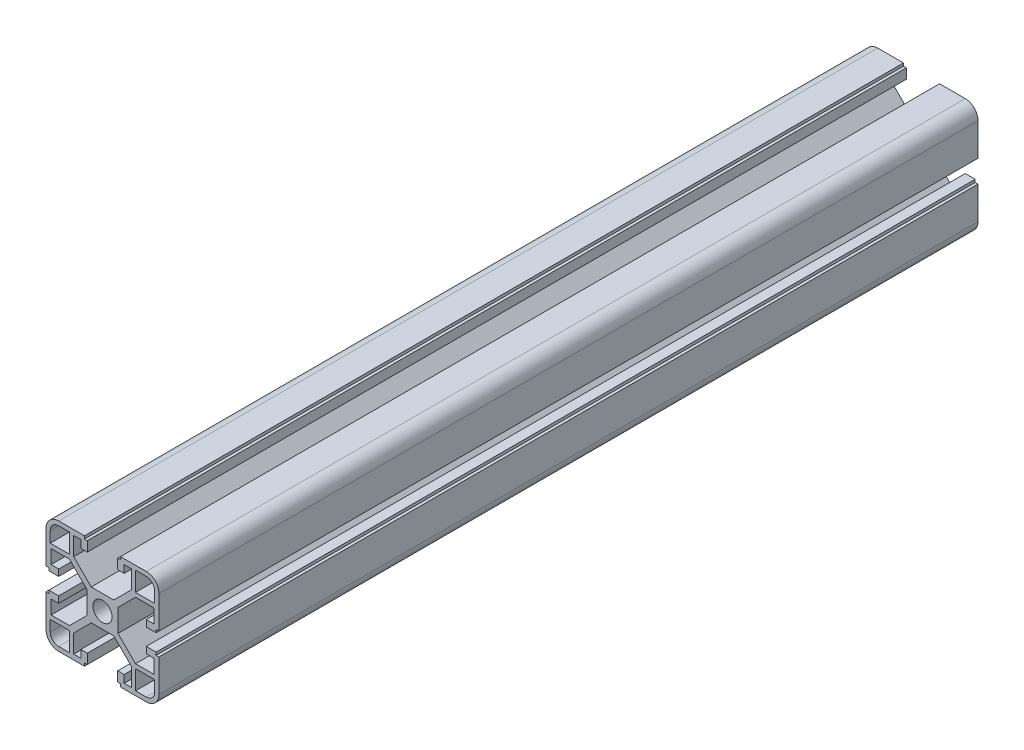
from build123d import *

# Parameters (mm, degrees)
BOSS_EXTRUDE1_DEPTH  = 290
MIRROR3_COPY_1_DEPTH = 290
MIRROR3_COPY_2_DEPTH = 290


with BuildPart() as part:
    # Sketch1 → Boss-Extrude1 (new body)
    with BuildSketch(Plane.XY):
        with BuildLine():
            Line((3.4, 0), (5.5, 0))
            Line((5.5, 0), (5.5, 4))
            Line((5.5, 4), (11.69, 10.19))
            Line((11.69, 10.19), (18.2, 10.19))
            Line((18.2, 10.19), (18.2, 5.265595036))
            Line((18.2, 5.265595036), (15.5, 5.265595036))
            Line((15.5, 5.265595036), (15.5, 2.965595036))
            Line((15.5, 2.965595036), (19, 2.965595036))
            Line((19, 2.965595036), (19, 3.965595036))
            Line((19, 3.965595036), (20, 3.965595036))
            Line((20, 3.965595036), (20, 15.5))
            ThreePointArc((20, 15.5), (18.681980515, 18.681980515), (15.5, 20))
            Line((15.5, 20), (6.385304712, 20))
            Line((6.385304712, 20), (6.385304712, 19))
            Line((6.385304712, 19), (5.385304712, 19))
            Line((5.385304712, 19), (5.385304712, 15.5))
            Line((5.385304712, 15.5), (7.685304712, 15.5))
            Line((7.685304712, 15.5), (7.685304712, 18.2))
            Line((7.685304712, 18.2), (10.19, 18.2))
            Line((10.19, 18.2), (10.19, 11.69))
            Line((10.19, 11.69), (4, 5.5))
            Line((4, 5.5), (0, 5.5))
            Line((0, 5.5), (0, 3.4))
            ThreePointArc((0, 3.4), (2.404163056, 2.404163056), (3.4, 0))
        make_face()
        with BuildLine():
            Line((18.5, 11.69), (18.5, 15.5))
            ThreePointArc((18.5, 15.5), (17.621320344, 17.621320344), (15.5, 18.5))
            Line((15.5, 18.5), (11.69, 18.5))
            Line((11.69, 18.5), (11.69, 11.69))
            Line((11.69, 11.69), (18.5, 11.69))
        make_face(mode=Mode.SUBTRACT)
    boss_extrude1 = extrude(amount=BOSS_EXTRUDE1_DEPTH)

    # Mirror1: Boss-Extrude1 across plane
    add(boss_extrude1.mirror(Plane.ZX))

    # Mirror2: Boss-Extrude1 across plane
    add(boss_extrude1.mirror(Plane(origin=(0, 0, 0), x_dir=(0, 0, 1), z_dir=(1, 0, 0))))

    # Mirror3 copy 1 sketch → Mirror3 copy 1 (add)
    with BuildSketch(Plane(origin=(0, 0, 0), x_dir=(-1, 0, 0), z_dir=(0, 0, 1))):
        with BuildLine():
            Line((3.4, 0), (5.5, 0))
            Line((5.5, 0), (5.5, 4))
            Line((5.5, 4), (11.69, 10.19))
            Line((11.69, 10.19), (18.2, 10.19))
            Line((18.2, 10.19), (18.2, 5.265595036))
            Line((18.2, 5.265595036), (15.5, 5.265595036))
            Line((15.5, 5.265595036), (15.5, 2.965595036))
            Line((15.5, 2.965595036), (19, 2.965595036))
            Line((19, 2.965595036), (19, 3.965595036))
            Line((19, 3.965595036), (20, 3.965595036))
            Line((20, 3.965595036), (20, 15.5))
            ThreePointArc((20, 15.5), (18.681980515, 18.681980515), (15.5, 20))
            Line((15.5, 20), (6.385304712, 20))
            Line((6.385304712, 20), (6.385304712, 19))
            Line((6.385304712, 19), (5.385304712, 19))
            Line((5.385304712, 19), (5.385304712, 15.5))
            Line((5.385304712, 15.5), (7.685304712, 15.5))
            Line((7.685304712, 15.5), (7.685304712, 18.2))
            Line((7.685304712, 18.2), (10.19, 18.2))
            Line((10.19, 18.2), (10.19, 11.69))
            Line((10.19, 11.69), (4, 5.5))
            Line((4, 5.5), (0, 5.5))
            Line((0, 5.5), (0, 3.4))
            ThreePointArc((0, 3.4), (2.404163056, 2.404163056), (3.4, 0))
        make_face()
        with BuildLine():
            Line((18.5, 11.69), (18.5, 15.5))
            ThreePointArc((18.5, 15.5), (17.621320344, 17.621320344), (15.5, 18.5))
            Line((15.5, 18.5), (11.69, 18.5))
            Line((11.69, 18.5), (11.69, 11.69))
            Line((11.69, 11.69), (18.5, 11.69))
        make_face(mode=Mode.SUBTRACT)
    extrude(amount=MIRROR3_COPY_1_DEPTH)

    # Mirror3 copy 2 sketch → Mirror3 copy 2 (add)
    with BuildSketch(Plane.XY):
        with BuildLine():
            Line((3.4, 0), (5.5, 0))
            Line((5.5, 0), (5.5, -4))
            Line((5.5, -4), (11.69, -10.19))
            Line((11.69, -10.19), (18.2, -10.19))
            Line((18.2, -10.19), (18.2, -5.265595036))
            Line((18.2, -5.265595036), (15.5, -5.265595036))
            Line((15.5, -5.265595036), (15.5, -2.965595036))
            Line((15.5, -2.965595036), (19, -2.965595036))
            Line((19, -2.965595036), (19, -3.965595036))
            Line((19, -3.965595036), (20, -3.965595036))
            Line((20, -3.965595036), (20, -15.5))
            ThreePointArc((20, -15.5), (18.681980515, -18.681980515), (15.5, -20))
            Line((15.5, -20), (6.385304712, -20))
            Line((6.385304712, -20), (6.385304712, -19))
            Line((6.385304712, -19), (5.385304712, -19))
            Line((5.385304712, -19), (5.385304712, -15.5))
            Line((5.385304712, -15.5), (7.685304712, -15.5))
            Line((7.685304712, -15.5), (7.685304712, -18.2))
            Line((7.685304712, -18.2), (10.19, -18.2))
            Line((10.19, -18.2), (10.19, -11.69))
            Line((10.19, -11.69), (4, -5.5))
            Line((4, -5.5), (0, -5.5))
            Line((0, -5.5), (0, -3.4))
            ThreePointArc((0, -3.4), (2.404163056, -2.404163056), (3.4, 0))
        make_face()
        with BuildLine():
            Line((18.5, -11.69), (18.5, -15.5))
            ThreePointArc((18.5, -15.5), (17.621320344, -17.621320344), (15.5, -18.5))
            Line((15.5, -18.5), (11.69, -18.5))
            Line((11.69, -18.5), (11.69, -11.69))
            Line((11.69, -11.69), (18.5, -11.69))
        make_face(mode=Mode.SUBTRACT)
    extrude(amount=MIRROR3_COPY_2_DEPTH)


solid = part.part
